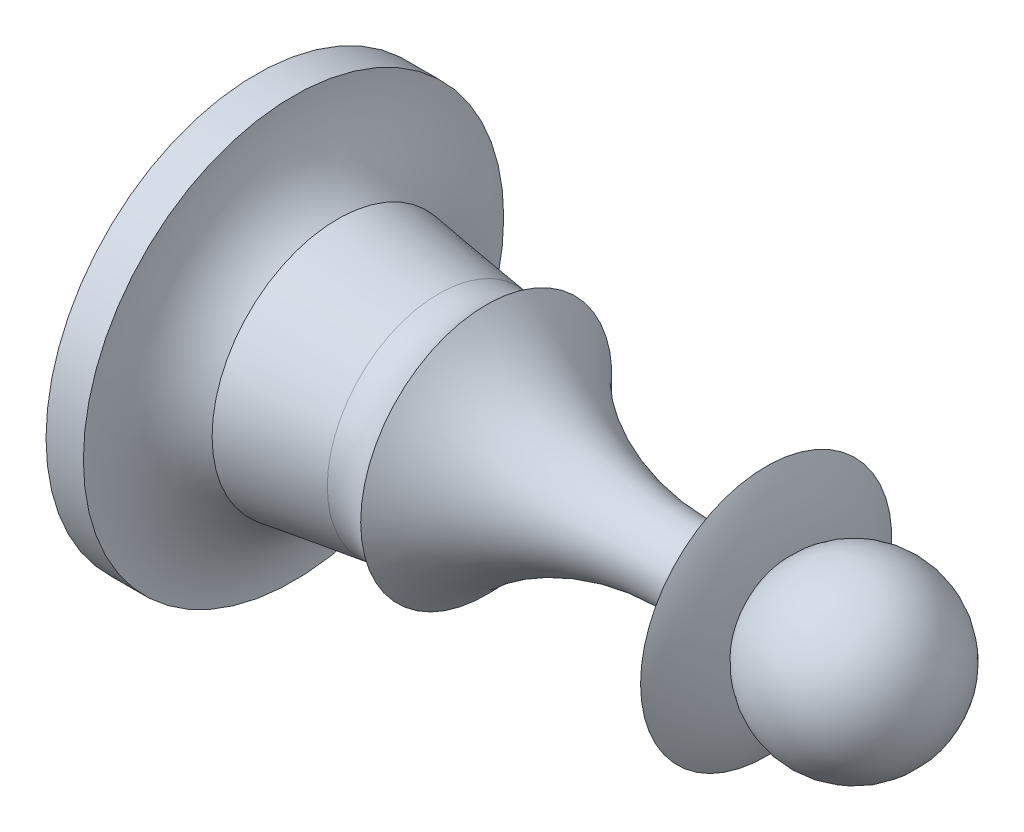
from build123d import *


with BuildPart() as part:
    # Sketch1 → Revolve3 (revolve)
    with BuildSketch(Plane(origin=(0, 0, 0), x_dir=(1, 0, 0), z_dir=(0, 1, 0)), mode=Mode.PRIVATE) as revolve3_sk:
        with BuildLine():
            Line((0, 0), (0, 50.33557047))
            Line((0, 50.33557047), (8.948545861, 50.33557047))
            ThreePointArc((8.948545861, 50.33557047), (11.752627589, 38.912973809), (19.527360349, 30.087322597))
            Line((19.527360349, 30.087322597), (43.711613675, 26.680404901))
            ThreePointArc((43.711613675, 26.680404901), (49.787589671, 27.137775211), (55.11927253, 30.087322597))
            ThreePointArc((55.11927253, 30.087322597), (83.391603839, 11.474230463), (117.225950783, 10.469798658))
            ThreePointArc((117.225950783, 10.469798658), (118.475150891, 20.582542828), (122.147651007, 30.087322597))
            ThreePointArc((122.147651007, 30.087322597), (125.665359446, 22.268883279), (127.366777858, 13.866059859))
            ThreePointArc((127.366777858, 13.866059859), (150.584616426, 19.681097455), (164.205816555, 0))
            Line((164.205816555, 0), (0, 0))
        make_face()
    revolve(revolve3_sk.sketch.rotate(Axis((0, 0, 0), (1, 0, 0)), 180), axis=Axis((0, 0, 0), (1, 0, 0)))  # turned: the seam where the file's is


solid = part.part
